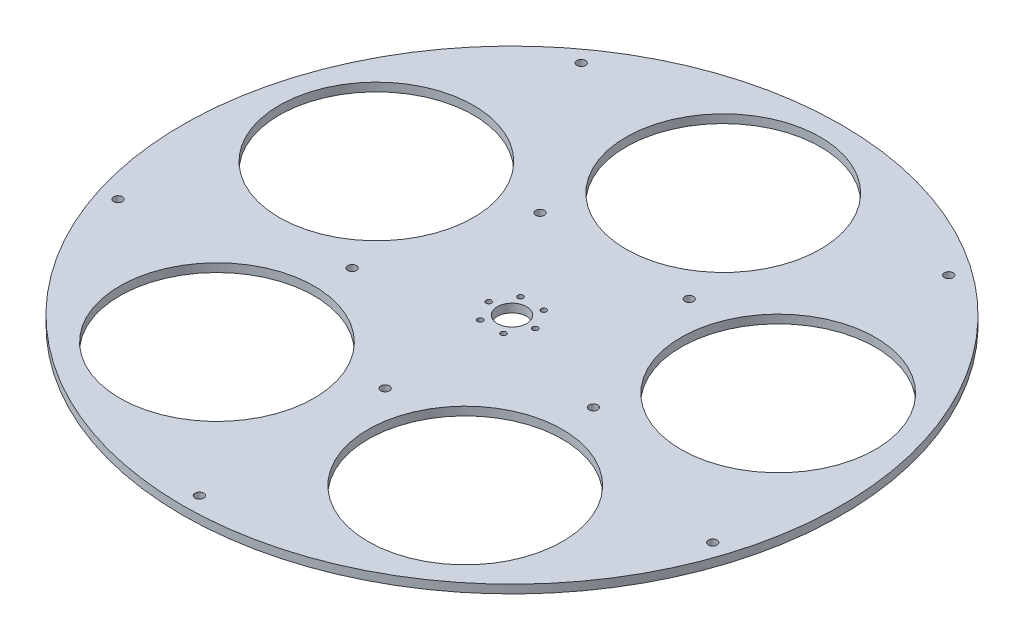
from build123d import *

# Parameters (mm, degrees)
SKETCH1_R              = 247.65
SKETCH1_R_2            = 73.025
BOSS_EXTRUDE1_DEPTH    = 6.35
SKETCH3_R              = 11
CUT_EXTRUDE1_DEPTH     = 7.35
F_10_32_TAPPED_HOLE1_D = 4.0386
SKETCH8_R              = 3.2512
CUT_EXTRUDE2_DEPTH     = 7.35
SKETCH9_R              = 3.2639
CUT_EXTRUDE3_DEPTH     = 7.35
CIRPATTERN1_COUNT      = 5


with BuildPart() as part:
    # Sketch1 → Boss-Extrude1 (new body)
    with BuildSketch(Plane(origin=(0, 0, 0), x_dir=(1, 0, 0), z_dir=(0, 1, 0))):
        Circle(SKETCH1_R)
        with Locations((0, 158.75)):
            Circle(SKETCH1_R_2, mode=Mode.SUBTRACT)
        with Locations((150.980221962, 49.056447857)):
            Circle(SKETCH1_R_2, mode=Mode.SUBTRACT)
        with Locations((93.310908801, -128.431447857)):
            Circle(SKETCH1_R_2, mode=Mode.SUBTRACT)
        with Locations((-93.310908801, -128.431447857)):
            Circle(SKETCH1_R_2, mode=Mode.SUBTRACT)
        with Locations((-150.980221962, 49.056447857)):
            Circle(SKETCH1_R_2, mode=Mode.SUBTRACT)
    extrude(amount=BOSS_EXTRUDE1_DEPTH)

    # Sketch3 → Cut-Extrude1 (cut, through all)
    with BuildSketch(Plane(origin=(-5.184519995, 6.35, -2.448578058), x_dir=(1, 0, 0), z_dir=(0, 1, 0))):
        with Locations((5.184519995, -2.448578058)):
            Circle(SKETCH3_R)
    extrude(amount=-CUT_EXTRUDE1_DEPTH, mode=Mode.SUBTRACT)

    # #10-32 Tapped Hole1 (through all)
    with Locations(Plane(origin=(-5.184519995, 6.35, -2.448578058), x_dir=(1, 0, 0), z_dir=(0, 1, 0))):
        with Locations((-3.546730005, 12.674390556), (13.915769995, 12.674390556), (22.647019995, -2.448578058), (13.915769995, -17.571546671), (-3.546730005, -17.571546671), (-12.277980005, -2.448578058)):
            Hole(F_10_32_TAPPED_HOLE1_D / 2)

    # Sketch8 → Cut-Extrude2 (cut, through all)
    with BuildSketch(Plane(origin=(0, 6.35, 0), x_dir=(1, 0, 0), z_dir=(0, 1, 0))):
        with Locations((0, -234.95)):
            Circle(SKETCH8_R)
        with Locations((-223.450728504, -72.603542828)):
            Circle(SKETCH8_R)
        with Locations((-138.100145026, 190.078542828)):
            Circle(SKETCH8_R)
        with Locations((138.100145026, 190.078542828)):
            Circle(SKETCH8_R)
        with Locations((223.450728504, -72.603542828)):
            Circle(SKETCH8_R)
    extrude(amount=-CUT_EXTRUDE2_DEPTH, mode=Mode.SUBTRACT)

    # Sketch9 → Cut-Extrude3 (cut, through all)
    with BuildSketch(Plane(origin=(0, 6.35, 0), x_dir=(1, 0, 0), z_dir=(0, 1, 0))):
        with Locations((0, -95.3389)):
            Circle(SKETCH9_R)
    cut_extrude3 = extrude(amount=-CUT_EXTRUDE3_DEPTH, mode=Mode.SUBTRACT)

    # CirPattern1: Cut-Extrude3 ×5 about axis
    cirpattern1_axis = Axis((0, 0, 0), (0, 1, 0))
    for i in range(1, CIRPATTERN1_COUNT):
        add(cut_extrude3.rotate(cirpattern1_axis, i * 360 / CIRPATTERN1_COUNT), mode=Mode.SUBTRACT)


solid = part.part
